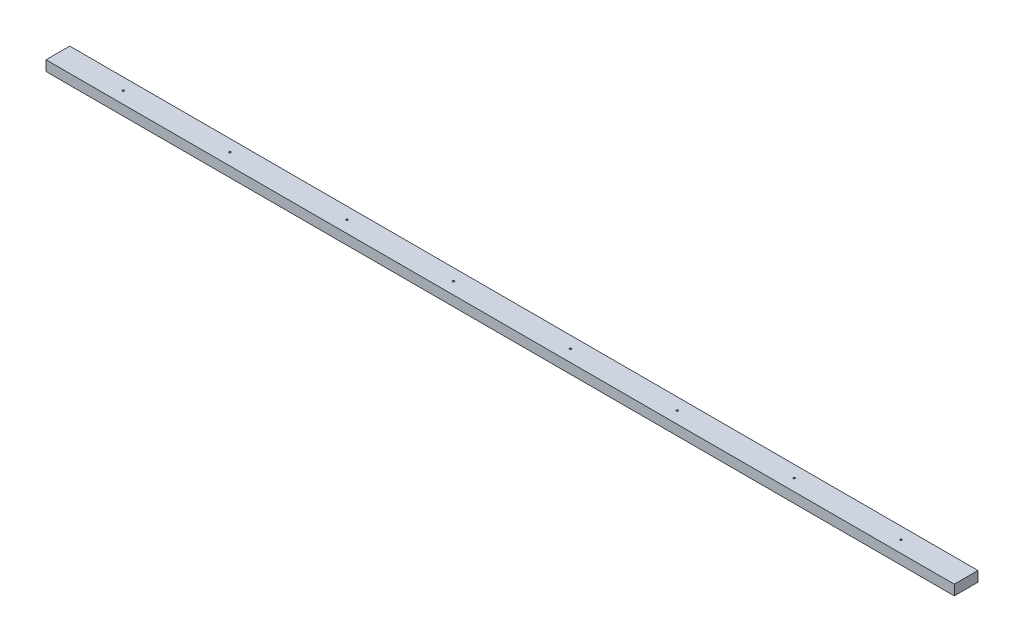
from build123d import *

# Parameters (mm, degrees)
SKETCH1_W           = 88.9
SKETCH1_H           = 38.1
BOSS_EXTRUDE1_DEPTH = 3403.6
SKETCH2_R           = 3.5815
CUT_EXTRUDE1_DEPTH  = 39.1


with BuildPart() as part:
    # Sketch1 → Boss-Extrude1 (new body)
    with BuildSketch(Plane(origin=(0, 0, 0), x_dir=(0, 0, -1), z_dir=(1, 0, 0))):
        Rectangle(SKETCH1_W, SKETCH1_H)
    extrude(amount=BOSS_EXTRUDE1_DEPTH)

    # Sketch2 → Cut-Extrude1 (cut, through all)
    with BuildSketch(Plane.XZ.offset(19.05)):
        with Locations((244.529, 0)):
            Circle(SKETCH2_R)
        with Locations((644.529, 0)):
            Circle(SKETCH2_R)
        with Locations((1082.729, 0)):
            Circle(SKETCH2_R)
        with Locations((1482.729, 0)):
            Circle(SKETCH2_R)
        with Locations((1920.929, 0)):
            Circle(SKETCH2_R)
        with Locations((2320.929, 0)):
            Circle(SKETCH2_R)
        with Locations((2759.129, 0)):
            Circle(SKETCH2_R)
        with Locations((3159.129, 0)):
            Circle(SKETCH2_R)
    extrude(amount=-CUT_EXTRUDE1_DEPTH, mode=Mode.SUBTRACT)


solid = part.part
